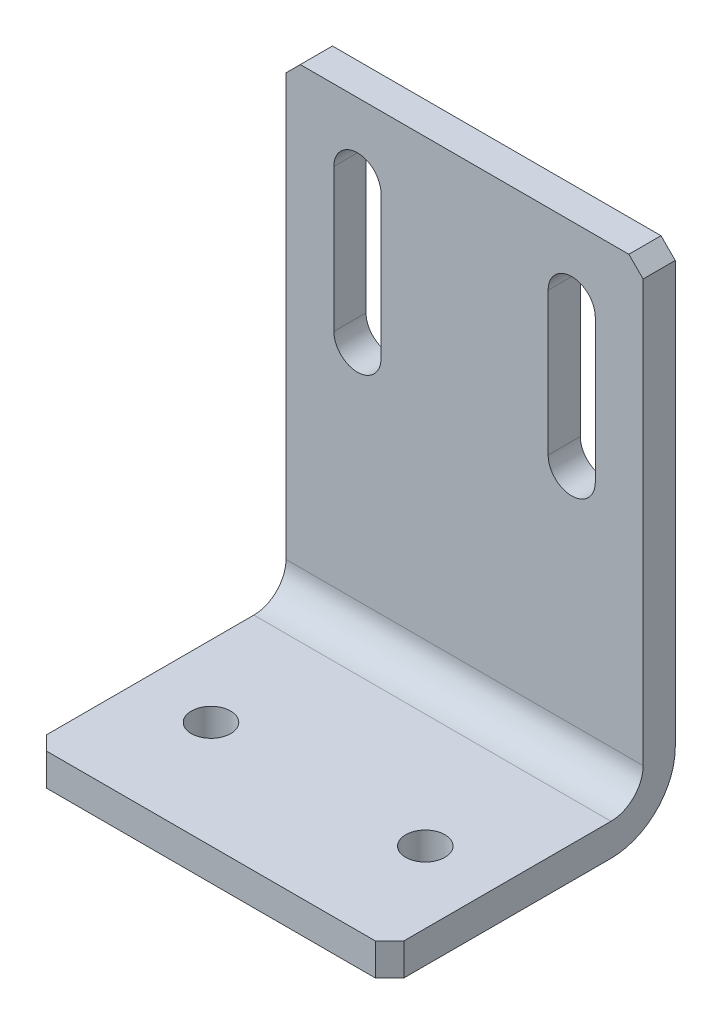
from build123d import *

# Parameters (mm, degrees)
BOSS_EXTRUDE1_DEPTH  = 25
FILLET1_R            = 4.5
FILLET2_R            = 9
M5_CLEARANCE_HOLE1_D = 5.5
CUT_EXTRUDE1_DEPTH   = 5.5
CHAMFER1_SIZE        = 2


with BuildPart() as part:
    # Sketch1 → Boss-Extrude1 (new body, symmetric)
    with BuildSketch(Plane(origin=(0, 0, 0), x_dir=(0, 0, -1), z_dir=(1, 0, 0))):
        Polygon((0, 0), (-40, 0), (-40, 4.5), (-4.5, 4.5), (-4.5, 70), (0, 70), align=None)
    extrude(amount=BOSS_EXTRUDE1_DEPTH, both=True)

    # Fillet1
    fillet1_edges = [part.edges().sort_by_distance(p)[0] for p in [
        (0, 4.5, 4.5),
    ]]
    fillet(fillet1_edges, radius=FILLET1_R)

    # Fillet2
    fillet2_edges = [part.edges().sort_by_distance(p)[0] for p in [
        (0, 0, 0),
    ]]
    fillet(fillet2_edges, radius=FILLET2_R)

    # M5 Clearance Hole1 (through all)
    with Locations(Plane(origin=(0, 4.5, 0), x_dir=(-1, 0, 0), z_dir=(0, 1, 0))):
        with Locations((15, 25), (-15, 25)):
            Hole(M5_CLEARANCE_HOLE1_D / 2)

    # Sketch4 → Cut-Extrude1 (cut, through all)
    with BuildSketch(Plane.XY.offset(4.5)):
        with BuildLine():
            Line((-11.7, 60), (-11.7, 40))
            ThreePointArc((-11.7, 40), (-15, 36.7), (-18.3, 40))
            Line((-18.3, 40), (-18.3, 60))
            ThreePointArc((-18.3, 60), (-15, 63.3), (-11.7, 60))
        make_face()
        with BuildLine():
            Line((18.3, 60), (18.3, 40))
            ThreePointArc((18.3, 40), (15, 36.7), (11.7, 40))
            Line((11.7, 40), (11.7, 60))
            ThreePointArc((11.7, 60), (15, 63.3), (18.3, 60))
        make_face()
    extrude(amount=-CUT_EXTRUDE1_DEPTH, mode=Mode.SUBTRACT)

    # Chamfer1
    chamfer1_edges = [part.edges().sort_by_distance(p)[0] for p in [
        (25, 2.25, 40),
        (25, 70, 2.25),
        (-25, 70, 2.25),
        (-25, 2.25, 40),
    ]]
    chamfer(chamfer1_edges, length=CHAMFER1_SIZE)


solid = part.part
